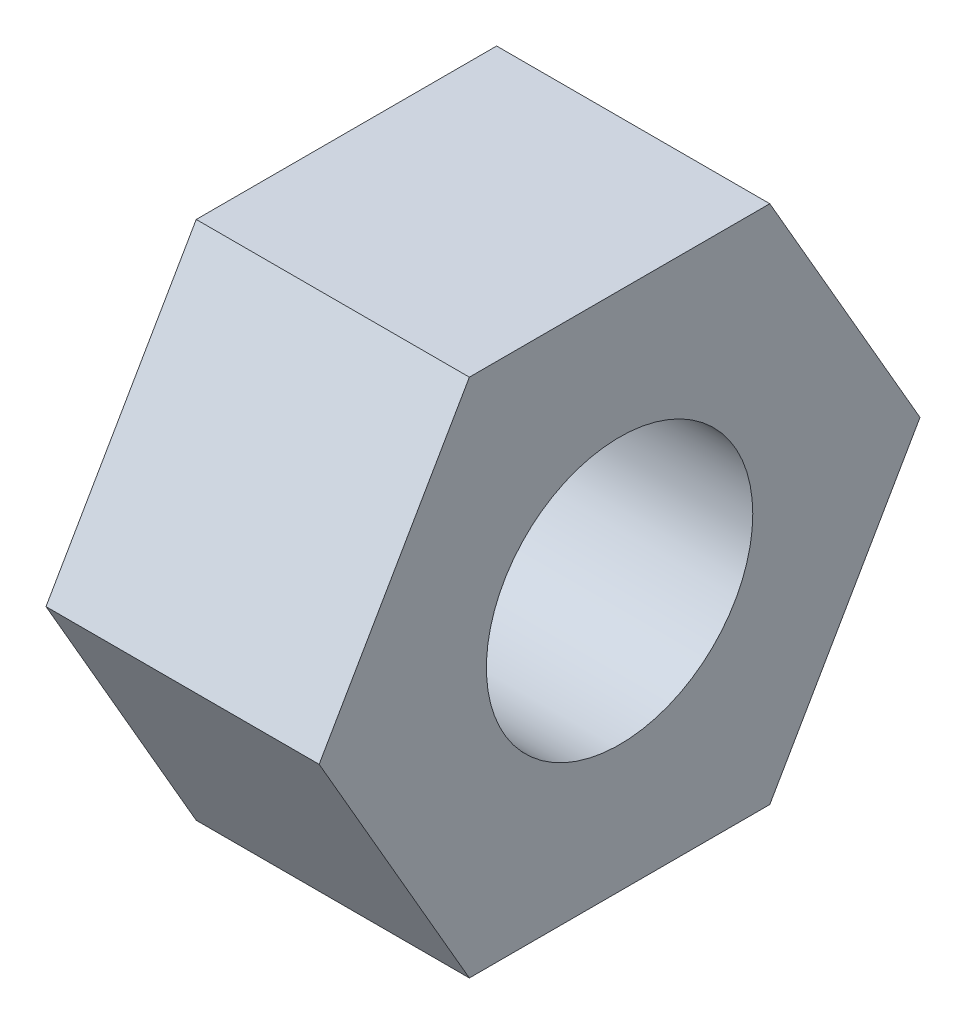
from build123d import *

# Parameters (mm, degrees)
BOSS_EXTRUDE1_DEPTH   = 2.5
F_2_CLEARANCE_HOLE1_D = 2.4384


with BuildPart() as part:
    # Sketch1 → Boss-Extrude1 (new body)
    with BuildSketch(Plane(origin=(0, 0, 0), x_dir=(0, 0, -1), z_dir=(1, 0, 0))):
        Polygon((2.749630657, 0), (1.374815329, 2.38125), (-1.374815329, 2.38125), (-2.749630657, 0), (-1.374815329, -2.38125), (1.374815329, -2.38125), align=None)
    extrude(amount=BOSS_EXTRUDE1_DEPTH)

    # #2 Clearance Hole1 (through all)
    with Locations(Plane(origin=(2.5, 0, 0), x_dir=(0, 0, -1), z_dir=(1, 0, 0))):
        with Locations((0, 0)):
            Hole(F_2_CLEARANCE_HOLE1_D / 2)


solid = part.part
